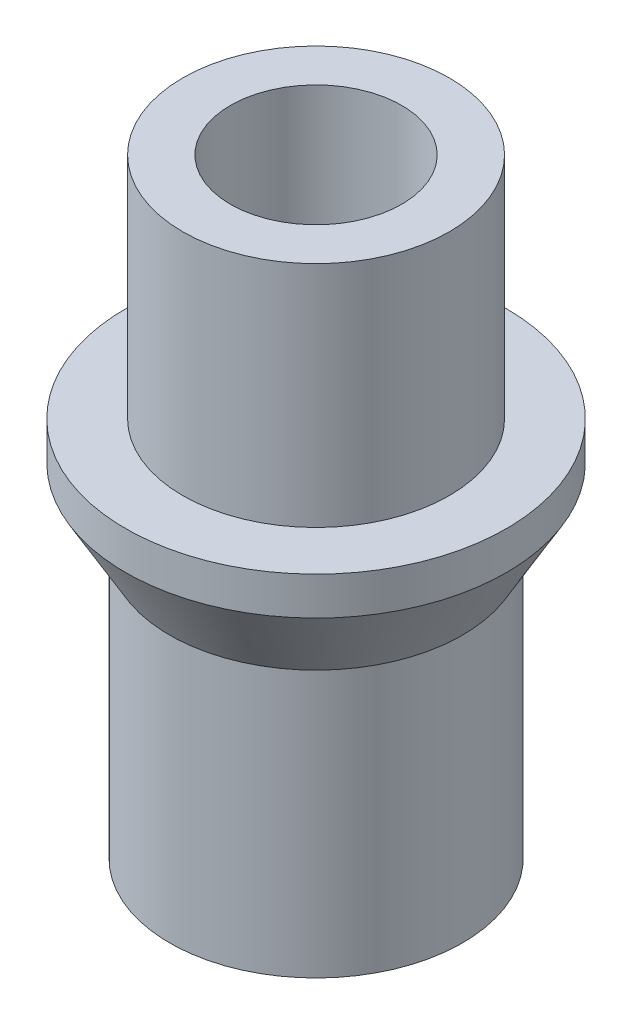
from build123d import *

# Parameters (mm, degrees)
SKETCH1_R           = 3.5
SKETCH1_R_2         = 2.25
BOSS_EXTRUDE1_DEPTH = 6
SKETCH2_R           = 5
BOSS_EXTRUDE2_DEPTH = 1
SKETCH4_R           = 5
BOSS_EXTRUDE4_DEPTH = 2
BOSS_EXTRUDE4_TAPER = 30
SKETCH5_R           = 3.845299462
BOSS_EXTRUDE5_DEPTH = 7


with BuildPart() as part:
    # Sketch1 → Boss-Extrude1 (new body)
    with BuildSketch(Plane(origin=(0, 0, 0), x_dir=(1, 0, 0), z_dir=(0, 1, 0))):
        Circle(SKETCH1_R)
        Circle(SKETCH1_R_2, mode=Mode.SUBTRACT)
    extrude(amount=-BOSS_EXTRUDE1_DEPTH)

    # Sketch2 → Boss-Extrude2 (add)
    with BuildSketch(Plane.XZ.offset(6)):
        Circle(SKETCH2_R)
    extrude(amount=BOSS_EXTRUDE2_DEPTH)

    # Sketch4 → Boss-Extrude4 (add)
    with BuildSketch(Plane.XZ.offset(7)):
        Circle(SKETCH4_R)
    extrude(amount=BOSS_EXTRUDE4_DEPTH, taper=BOSS_EXTRUDE4_TAPER)

    # Sketch5 → Boss-Extrude5 (add)
    with BuildSketch(Plane.XZ.offset(9)):
        Circle(SKETCH5_R)
    extrude(amount=BOSS_EXTRUDE5_DEPTH)


solid = part.part
